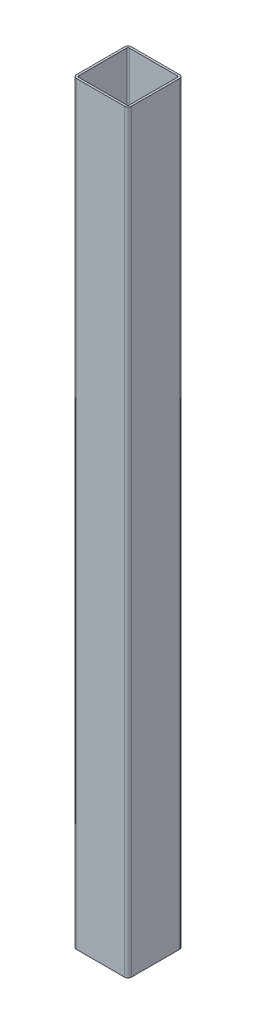
from build123d import *

# Parameters (mm, degrees)
EXTRUDE_1_DEPTH = 1100


with BuildPart() as part:
    # Эскиз1 → Вытянуть-Тонкостенный1 (new body)
    with BuildSketch(Plane(origin=(0, 0, 0), x_dir=(1, 0, 0), z_dir=(0, 1, 0))):
        with BuildLine():
            Line((-35, 40), (35, 40))
            ThreePointArc((35, 40), (38.535533906, 38.535533906), (40, 35))
            Line((40, 35), (40, -35))
            ThreePointArc((40, -35), (38.535533906, -38.535533906), (35, -40))
            Line((35, -40), (-35, -40))
            ThreePointArc((-35, -40), (-38.535533906, -38.535533906), (-40, -35))
            Line((-40, -35), (-40, 35))
            ThreePointArc((-40, 35), (-38.535533906, 38.535533906), (-35, 40))
        make_face()
        with BuildLine():
            Line((-35, 37), (35, 37))
            ThreePointArc((35, 37), (36.414213562, 36.414213562), (37, 35))
            Line((37, 35), (37, -35))
            ThreePointArc((37, -35), (36.414213562, -36.414213562), (35, -37))
            Line((35, -37), (-35, -37))
            ThreePointArc((-35, -37), (-36.414213562, -36.414213562), (-37, -35))
            Line((-37, -35), (-37, 35))
            ThreePointArc((-37, 35), (-36.414213562, 36.414213562), (-35, 37))
        make_face(mode=Mode.SUBTRACT)
    extrude(amount=EXTRUDE_1_DEPTH)


solid = part.part
